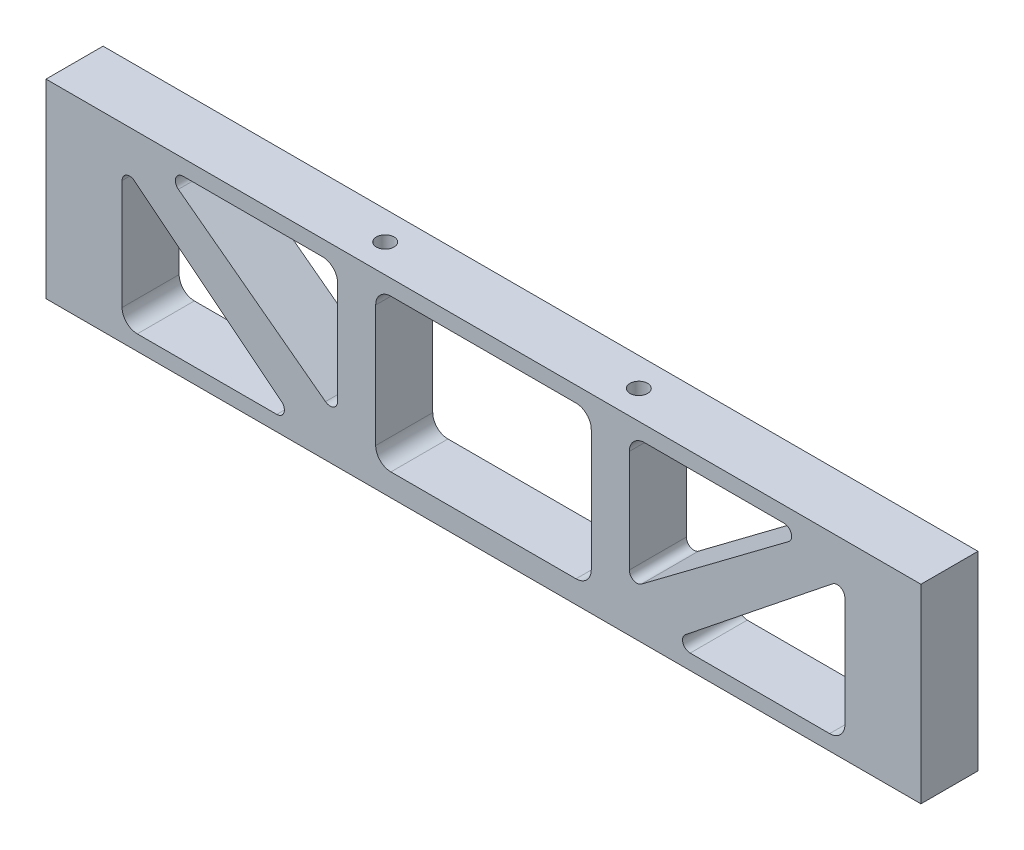
from build123d import *

# Parameters (mm, degrees)
BOSS_EXTRUDE2_DEPTH                        = 9.525
SKETCH4_R                                  = 1.4732
CUT_EXTRUDE2_DEPTH                         = 12.7
MIRROR2_AT_THE_SECOND_PLANE_COPY_1_SKETC_R = 1.4732
MIRROR2_AT_THE_SECOND_PLANE_COPY_1_DEPTH   = 12.7


with BuildPart() as part:
    # Sketch2 → Boss-Extrude2 (new body)
    with BuildSketch(Plane.XY):
        Polygon((-63.5, 15.299999878), (-73.025, 15.299999878), (-73.025, -16.450000122), (-63.5, -16.450000122), (-21.166666667, -16.450000122), (0, -16.450000122), (73.025, -16.450000122), (73.025, 15.299999878), (-21.166666667, 15.299999878), (-24.341666667, 15.299999878), align=None)
        with BuildLine():
            ThreePointArc((-57.785, -13.912500244), (-59.581051224, -13.168551468), (-60.325, -11.372500244))
            Line((-60.325, -11.372500244), (-60.325, 6.985))
            ThreePointArc((-60.325, 6.985), (-59.605365306, 8.129551454), (-58.262010976, 7.977002221))
            Line((-58.262010976, 7.977002221), (-33.708677642, -11.650498023))
            ThreePointArc((-33.708677642, -11.650498023), (-33.303179533, -13.062653299), (-34.501666667, -13.912500244))
            Line((-34.501666667, -13.912500244), (-57.785, -13.912500244))
        make_face(mode=Mode.SUBTRACT)
        with BuildLine():
            ThreePointArc((60.325, -11.372500244), (59.581051224, -13.168551468), (57.785, -13.912500244))
            Line((57.785, -13.912500244), (34.501666667, -13.912500244))
            ThreePointArc((34.501666667, -13.912500244), (33.303179533, -13.062653299), (33.708677642, -11.650498023))
            Line((33.708677642, -11.650498023), (58.262010976, 7.977002221))
            ThreePointArc((58.262010976, 7.977002221), (59.605365306, 8.129551454), (60.325, 6.985))
            Line((60.325, 6.985), (60.325, -11.372500244))
        make_face(mode=Mode.SUBTRACT)
        with BuildLine():
            Line((-26.373666667, -8.001), (-50.927, 10.414))
            ThreePointArc((-50.927, 10.414), (-51.369827789, 11.831609263), (-50.165, 12.7))
            Line((-50.165, 12.7), (-26.881666667, 12.7))
            ThreePointArc((-26.881666667, 12.7), (-25.085615442, 11.956051224), (-24.341666667, 10.16))
            Line((-24.341666667, 10.16), (-24.341666667, -6.985))
            ThreePointArc((-24.341666667, -6.985), (-25.0437054, -8.120922533), (-26.373666667, -8.001))
        make_face(mode=Mode.SUBTRACT)
        with BuildLine():
            ThreePointArc((-17.991666667, 10.16), (-17.247717891, 11.956051224), (-15.451666667, 12.7))
            Line((-15.451666667, 12.7), (15.451666667, 12.7))
            ThreePointArc((15.451666667, 12.7), (17.247717891, 11.956051224), (17.991666667, 10.16))
            Line((17.991666667, 10.16), (17.991666667, -10.16))
            ThreePointArc((17.991666667, -10.16), (17.247717891, -11.956051224), (15.451666667, -12.7))
            Line((15.451666667, -12.7), (-15.451666667, -12.7))
            ThreePointArc((-15.451666667, -12.7), (-17.247717891, -11.956051224), (-17.991666667, -10.16))
            Line((-17.991666667, -10.16), (-17.991666667, 10.16))
        make_face(mode=Mode.SUBTRACT)
        with BuildLine():
            Line((24.341666667, -6.985), (24.341666667, 10.16))
            ThreePointArc((24.341666667, 10.16), (25.085615442, 11.956051224), (26.881666667, 12.7))
            Line((26.881666667, 12.7), (50.165, 12.7))
            ThreePointArc((50.165, 12.7), (51.369827789, 11.831609263), (50.927, 10.414))
            Line((50.927, 10.414), (26.373666667, -8.001))
            ThreePointArc((26.373666667, -8.001), (25.0437054, -8.120922533), (24.341666667, -6.985))
        make_face(mode=Mode.SUBTRACT)
    extrude(amount=BOSS_EXTRUDE2_DEPTH)

    # Sketch4 → Cut-Extrude2 (cut)
    with BuildSketch(Plane(origin=(0, 15.299999878, 0), x_dir=(1, 0, 0), z_dir=(0, 1, 0))):
        with Locations((21.166666667, -4.7625)):
            Circle(SKETCH4_R)
    cut_extrude2 = extrude(amount=-CUT_EXTRUDE2_DEPTH, mode=Mode.SUBTRACT)

    # Mirror2: Cut-Extrude2 across plane
    add(cut_extrude2.mirror(Plane.ZX.offset(-0.575000122)), mode=Mode.SUBTRACT)

    # Mirror2 at the second plane: Cut-Extrude2 across plane
    add(cut_extrude2.mirror(Plane(origin=(0, 0, 0), x_dir=(0, 0, 1), z_dir=(1, 0, 0))), mode=Mode.SUBTRACT)

    # Mirror2 at the second plane copy 1 sketc → Mirror2 at the second plane copy 1 (cut)
    with BuildSketch(Plane(origin=(0, -16.450000122, 0), x_dir=(-1, 0, 0), z_dir=(0, -1, 0))):
        with Locations((21.166666667, -4.7625)):
            Circle(MIRROR2_AT_THE_SECOND_PLANE_COPY_1_SKETC_R)
    extrude(amount=-MIRROR2_AT_THE_SECOND_PLANE_COPY_1_DEPTH, mode=Mode.SUBTRACT)


solid = part.part
